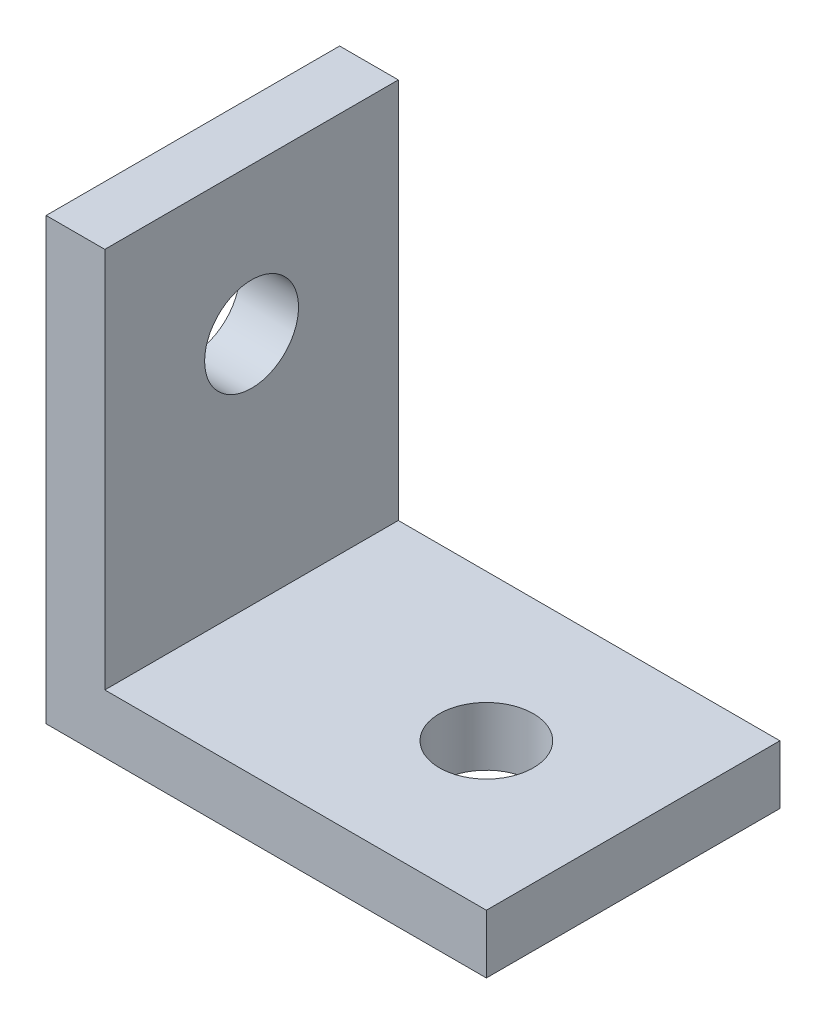
from build123d import *

# Parameters (mm, degrees)
BASE_DEPTH                       = 5
F_3_2_3_2_MOUNTHOLES_D           = 3.2
F_3_2_3_2_MOUNTHOLES_ON_FACE_2_D = 3.2


with BuildPart() as part:
    # Sketch1 → Base (new body, symmetric)
    with BuildSketch(Plane.XY):
        Polygon((0, 0), (0, 15), (2, 15), (2, 2), (15, 2), (15, 0), align=None)
    extrude(amount=BASE_DEPTH, both=True)

    # Ø3.2 (3.2) MountHoles (through all)
    with Locations(Plane(origin=(0, 10, 0), x_dir=(0, 0, -1), z_dir=(-1, 0, 0))):
        with Locations((0, 0)):
            Hole(F_3_2_3_2_MOUNTHOLES_D / 2)

    # Ø3.2 (3.2) MountHoles on face 2 (through all)
    with Locations(Plane(origin=(10, 0, 0), x_dir=(0, 0, -1), z_dir=(0, -1, 0))):
        with Locations((0, 0)):
            Hole(F_3_2_3_2_MOUNTHOLES_ON_FACE_2_D / 2)


solid = part.part
